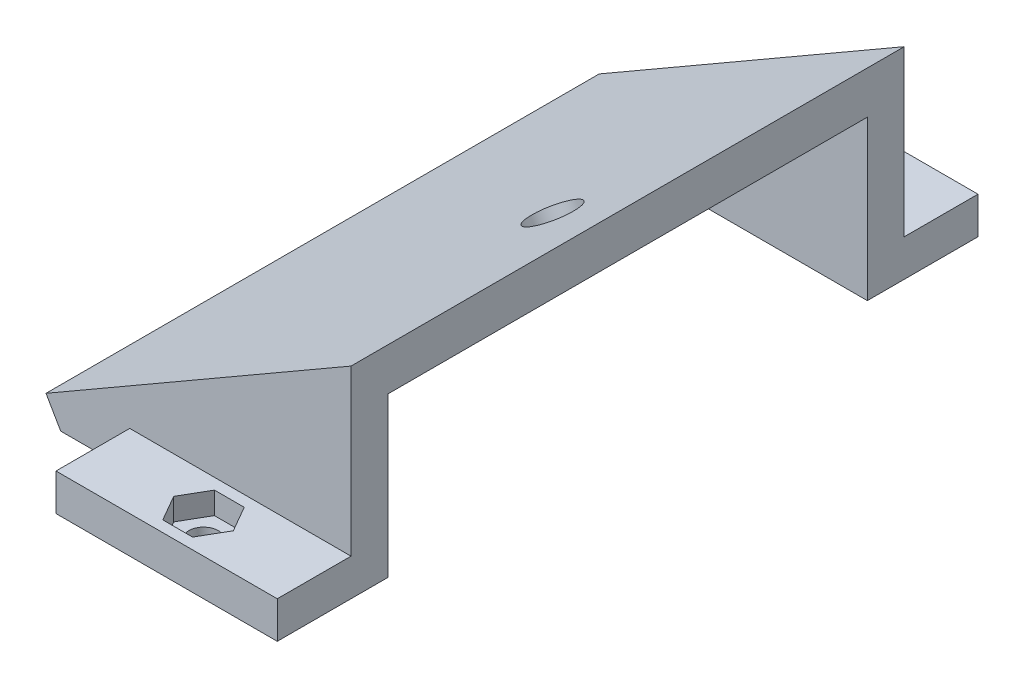
from build123d import *

# Parameters (mm, degrees)
EXTRUDE_1_DEPTH     = 75
SHELL_1_T           = -5
SKETCH_2_W          = 65
SKETCH_2_H          = 5
CUT_EXTRUDE_1_DEPTH = 25
SKETCH_3_R          = 3.25
CUT_EXTRUDE_2_DEPTH = 21
SKETCH_4_W          = 30
SKETCH_4_H          = 5
EXTRUDE_2_DEPTH     = 10
EXTRUDE_3_DEPTH     = 75
SKETCH_8_R          = 2
CUT_EXTRUDE_4_DEPTH = 6
CUT_EXTRUDE_5_DEPTH = 3


with BuildPart() as part:
    # 草图1 → 凸台-拉伸1 (new body)
    with BuildSketch(Plane.XY):
        Polygon((0, 0), (30, 0), (30, 27.320508076), (0, 10), align=None)
    extrude(amount=EXTRUDE_1_DEPTH)

    # 抽壳1
    shell_1_openings = [part.faces().sort_by_distance(p)[0] for p in [
        (30, 13.660254038, 37.5),
    ]]
    offset(amount=SHELL_1_T, openings=shell_1_openings, kind=Kind.INTERSECTION)

    # 草图2 → 切除-拉伸1 (cut)
    with BuildSketch(Plane(origin=(30, 0, 0), x_dir=(0, 0, -1), z_dir=(1, 0, 0))):
        with Locations((-37.5, 2.5)):
            Rectangle(SKETCH_2_W, SKETCH_2_H)
    extrude(amount=-CUT_EXTRUDE_1_DEPTH, mode=Mode.SUBTRACT)

    # 草图3 → 切除-拉伸2 (cut, through all)
    with BuildSketch(Plane(origin=(-1.830127019, 3.169872981, 0), x_dir=(0.866025404, 0.5, 0), z_dir=(0.5, -0.866025404, 0))):
        with Locations((27.886751346, 37.5)):
            Circle(SKETCH_3_R)
    extrude(amount=-CUT_EXTRUDE_2_DEPTH, mode=Mode.SUBTRACT)

    # 草图4 → 凸台-拉伸2 (add)
    with BuildSketch(Plane.XY.offset(75)):
        with Locations((15, 2.5)):
            Rectangle(SKETCH_4_W, SKETCH_4_H)
    extrude_2 = extrude(amount=EXTRUDE_2_DEPTH)

    # 镜向1: 凸台-拉伸2 across plane
    add(extrude_2.mirror(Plane.XY.offset(37.5)))

    # 草图5 → 凸台-拉伸3 (add)
    with BuildSketch(Plane.XY.offset(75)):
        Polygon((0, 10), (-11.353593044, 3.445), (-9.364621366, 0), (0, 0), align=None)
    extrude(amount=-EXTRUDE_3_DEPTH)

    # 草图8 → 切除-拉伸4 (cut, through all)
    with BuildSketch(Plane(origin=(0, 5, 0), x_dir=(1, 0, 0), z_dir=(0, 1, 0))):
        with Locations((15, 5)):
            Circle(SKETCH_8_R)
    cut_extrude_4 = extrude(amount=-CUT_EXTRUDE_4_DEPTH, mode=Mode.SUBTRACT)

    # 草图9 → 切除-拉伸5 (cut)
    with BuildSketch(Plane(origin=(0, 5, 0), x_dir=(1, 0, 0), z_dir=(0, 1, 0))):
        Polygon((17.020725942, 8.5), (12.979274058, 8.5), (10.958548116, 5), (12.979274058, 1.5), (17.020725942, 1.5), (19.041451884, 5), align=None)
    cut_extrude_5 = extrude(amount=-CUT_EXTRUDE_5_DEPTH, mode=Mode.SUBTRACT)

    # 镜向2: 切除-拉伸4, 切除-拉伸5 across plane
    add(cut_extrude_4.mirror(Plane.XY.offset(37.5)), mode=Mode.SUBTRACT)
    add(cut_extrude_5.mirror(Plane.XY.offset(37.5)), mode=Mode.SUBTRACT)


solid = part.part
